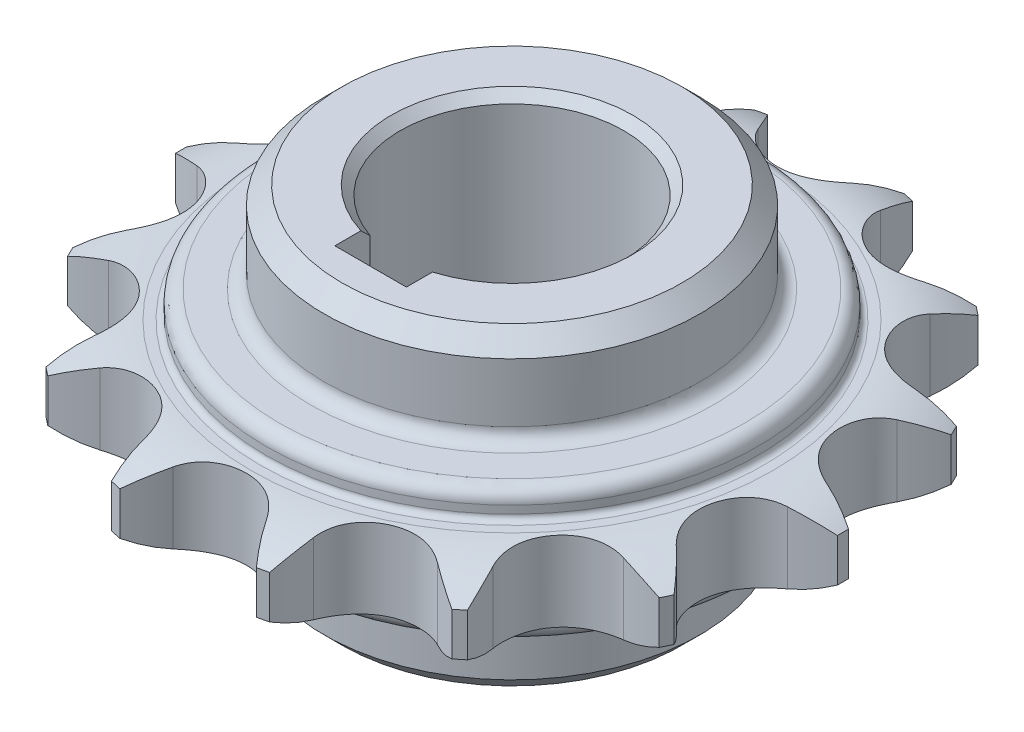
from build123d import *

# Parameters (mm, degrees)
EXTRUDE_1_DEPTH          = 8.93
PATTERN_CIRCULAR_1_COUNT = 14
SKETCH_4_R               = 27.5
EXTRUDE_3_DEPTH          = 3
SKETCH_3_R               = 27.5
EXTRUDE_2_DEPTH          = 3
SKETCH_5_R               = 21
EXTRUDE_4_DEPTH          = 10.07
FILLET_1_R               = 0.635
FILLET_2_R               = 1.5
CHAMFER_1_SIZE           = 2
SKETCH_6_R               = 12.5
CUT_EXTRUDE_3_DEPTH      = 40
CUT_EXTRUDE_4_REACH      = 27
SKETCH_9_R               = 21
EXTRUDE_5_DEPTH          = 10.07
CUT_EXTRUDE_5_REACH      = 12.07
CHAMFER_2_SIZE           = 2
FILLET_3_R               = 1.5
CHAMFER_3_SIZE           = 1


with BuildPart() as part:
    # 草图1 → 凸台-拉伸1 (new body)
    with BuildSketch(Plane(origin=(0, 0, 0), x_dir=(1, 0, 0), z_dir=(0, 1, 0))):
        with BuildLine():
            Line((0, 29.67085), (0, 0))
            Line((0, 0), (12.873699341, 26.732512134))
            ThreePointArc((12.873699341, 26.732512134), (10.51956913, 28.758404993), (9.493778992, 31.68994478))
            ThreePointArc((9.493778992, 31.68994478), (9.248307253, 33.823053422), (8.834109534, 35.929911059))
            ThreePointArc((8.834109534, 35.929911059), (8.233274556, 36.072332751), (7.630146491, 36.204707767))
            ThreePointArc((7.630146491, 36.204707767), (6.342835971, 34.486208283), (5.196152423, 32.67085))
            ThreePointArc((5.196152423, 32.67085), (3, 30.474697577), (0, 29.67085))
        make_face()
    extrude_1 = extrude(amount=EXTRUDE_1_DEPTH)

    # 阵列(圆周)1: 凸台-拉伸1 ×14 about axis
    pattern_circular_1_axis = Axis((0, 0, 0), (0, 1, 0))
    for i in range(1, PATTERN_CIRCULAR_1_COUNT):
        add(extrude_1.rotate(pattern_circular_1_axis, i * 360 / PATTERN_CIRCULAR_1_COUNT))

    # 草图2 → 切除-旋转1 (revolve, cut)
    with BuildSketch(Plane.XY):
        with BuildLine():
            Line((36.994847478, 8.93), (29.167651401, 8.93))
            ThreePointArc((29.167651401, 8.93), (33.21499814, 8.405394437), (36.994847478, 6.86625))
            Line((36.994847478, 6.86625), (36.994847478, 2.06375))
            ThreePointArc((36.994847478, 2.06375), (33.21499814, 0.524605563), (29.167651401, 0))
            Line((29.167651401, 0), (36.994847478, 0))
            Line((36.994847478, 0), (43.746655318, 0))
            Line((43.746655318, 0), (43.746655318, 8.93))
            Line((43.746655318, 8.93), (36.994847478, 8.93))
        make_face()
    revolve(axis=Axis((0, 0, 0), (0, 1, 0)), mode=Mode.SUBTRACT)

    # 草图4 → 凸台-拉伸3 (add)
    with BuildSketch(Plane.XZ):
        Circle(SKETCH_4_R)
    extrude(amount=EXTRUDE_3_DEPTH)

    # 草图3 → 凸台-拉伸2 (add)
    with BuildSketch(Plane(origin=(0, 8.93, 0), x_dir=(1, 0, 0), z_dir=(0, 1, 0))):
        Circle(SKETCH_3_R)
    extrude(amount=EXTRUDE_2_DEPTH)

    # 草图5 → 凸台-拉伸4 (add)
    with BuildSketch(Plane(origin=(0, 11.93, 0), x_dir=(1, 0, 0), z_dir=(0, 1, 0))):
        Circle(SKETCH_5_R)
    extrude(amount=EXTRUDE_4_DEPTH)

    # 圆角1
    fillet_1_edges = [part.edges().sort_by_distance(p)[0] for p in [
        (-27.5, 0, 0),
        (-27.5, 8.93, 0),
    ]]
    fillet(fillet_1_edges, radius=FILLET_1_R)

    # 圆角2
    fillet_2_edges = [part.edges().sort_by_distance(p)[0] for p in [
        (-27.5, -3, 0),
        (-27.5, 11.93, 0),
        (-21, 11.93, 0),
    ]]
    fillet(fillet_2_edges, radius=FILLET_2_R)

    # 倒角1
    chamfer_1_edges = [part.edges().sort_by_distance(p)[0] for p in [
        (-21, 22, 0),
    ]]
    chamfer(chamfer_1_edges, length=CHAMFER_1_SIZE)

    # 草图6 → 切除-拉伸3 (cut)
    with BuildSketch(Plane(origin=(0, 22, 0), x_dir=(1, 0, 0), z_dir=(0, 1, 0))):
        Circle(SKETCH_6_R)
    extrude(amount=-CUT_EXTRUDE_3_DEPTH, mode=Mode.SUBTRACT)

    # 草图7 → 切除-拉伸4 (cut, up to next)
    with BuildSketch(Plane.XZ.offset(3), mode=Mode.PRIVATE) as cut_extrude_4_sk1:
        with BuildLine():
            Line((-4, 11.842719282), (-4, 15.8))
            Line((-4, 15.8), (4, 15.8))
            Line((4, 15.8), (4, 11.842719282))
            ThreePointArc((4, 11.842719282), (0, 12.5), (-4, 11.842719282))
        make_face()
    cut_extrude_4_tool1 = extrude(cut_extrude_4_sk1.sketch, amount=-CUT_EXTRUDE_4_REACH, mode=Mode.PRIVATE) & part.part
    add(cut_extrude_4_tool1.solids().sort_by_distance((0, -3, 14.036215))[0], mode=Mode.SUBTRACT)

    # 草图9 → 凸台-拉伸5 (add)
    with BuildSketch(Plane.XZ.offset(3)):
        Circle(SKETCH_9_R)
    extrude(amount=EXTRUDE_5_DEPTH)

    # 草图10 → 切除-拉伸5 (cut, up to next)
    with BuildSketch(Plane(origin=(0, -3, 0), x_dir=(1, 0, 0), z_dir=(0, 1, 0)), mode=Mode.PRIVATE) as cut_extrude_5_sk1:
        with BuildLine():
            Line((-4, -15.8), (4, -15.8))
            Line((4, -15.8), (4, -11.842719282))
            ThreePointArc((4, -11.842719282), (0, 12.5), (-4, -11.842719282))
            Line((-4, -11.842719282), (-4, -15.8))
        make_face()
    cut_extrude_5_tool1 = extrude(cut_extrude_5_sk1.sketch, amount=-CUT_EXTRUDE_5_REACH, mode=Mode.PRIVATE) & part.part
    add(cut_extrude_5_tool1.solids().sort_by_distance((0, -3, 0.760862))[0], mode=Mode.SUBTRACT)

    # 倒角2
    chamfer_2_edges = [part.edges().sort_by_distance(p)[0] for p in [
        (-21, -13.07, 0),
    ]]
    chamfer(chamfer_2_edges, length=CHAMFER_2_SIZE)

    # 圆角3
    fillet_3_edges = [part.edges().sort_by_distance(p)[0] for p in [
        (-21, -3, 0),
    ]]
    fillet(fillet_3_edges, radius=FILLET_3_R)

    # 倒角3
    chamfer_3_edges = [part.edges().sort_by_distance(p)[0] for p in [
        (0, 22, -12.5),
        (0, -13.07, -12.5),
    ]]
    chamfer(chamfer_3_edges, length=CHAMFER_3_SIZE)


solid = part.part
